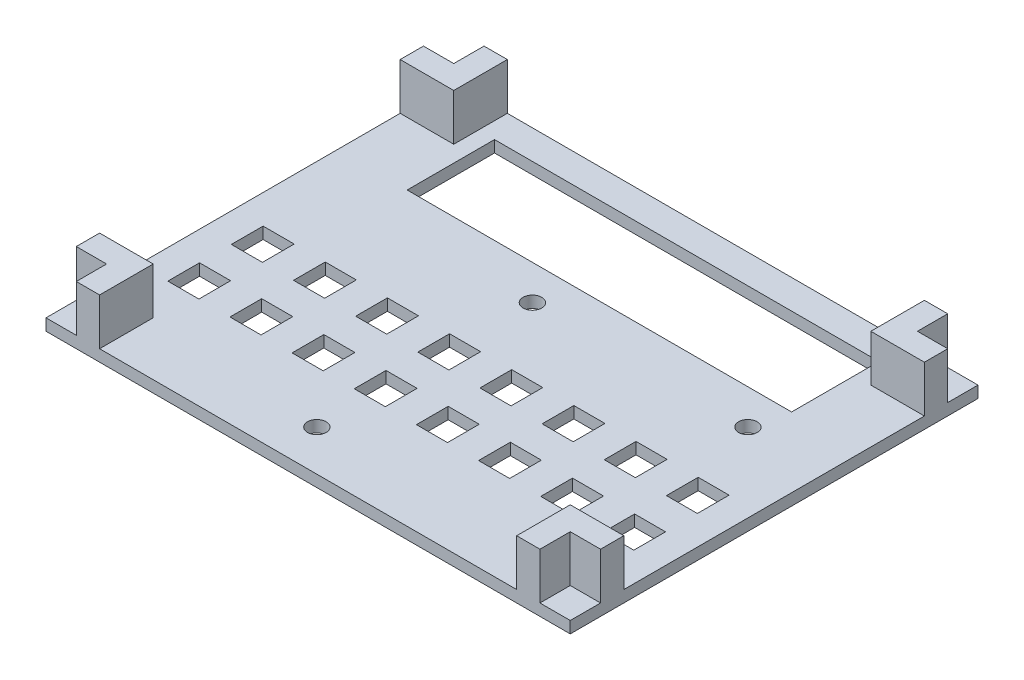
from build123d import *

# Parameters (mm, degrees)
ESBO_O1_W                = 90
ESBO_O1_H                = 70
RESSALTO_EXTRUS_O1_DEPTH = 2
RESSALTO_EXTRUS_O4_DEPTH = 8
ESBO_O6_W                = 66
ESBO_O6_H                = 15
CORTE_EXTRUS_O4_DEPTH    = 3
ESBO_O2_W                = 5.334
ESBO_O2_H                = 5.45
ESBO_O2_W_2              = 5.31
CORTE_EXTRUS_O6_DEPTH    = 5
ESBO_O7_R                = 1.6
CORTE_EXTRUS_O7_DEPTH    = 3


with BuildPart() as part:
    # Esboço1 → Ressalto-extrusão1 (new body)
    with BuildSketch(Plane(origin=(0, 0, 0), x_dir=(1, 0, 0), z_dir=(0, 1, 0))):
        Rectangle(ESBO_O1_W, ESBO_O1_H)
    extrude(amount=RESSALTO_EXTRUS_O1_DEPTH)

    # Esboço3 → Ressalto-extrusão4 (add)
    with BuildSketch(Plane(origin=(0, 2, 0), x_dir=(1, 0, 0), z_dir=(0, 1, 0))):
        Polygon((-35.8, -25.8), (-45, -25.8), (-45, -29.8), (-39.8, -29.8), (-39.8, -35), (-35.8, -35), align=None)
        Polygon((45, -29.8), (45, -25.8), (35.8, -25.8), (35.8, -35), (39.8, -35), (39.8, -29.8), align=None)
        Polygon((39.8, 35), (35.8, 35), (35.8, 25.8), (45, 25.8), (45, 29.8), (39.8, 29.8), align=None)
        Polygon((-35.8, 35), (-39.8, 35), (-39.8, 29.8), (-45, 29.8), (-45, 25.8), (-35.8, 25.8), align=None)
    extrude(amount=RESSALTO_EXTRUS_O4_DEPTH)

    # Esboço6 → Corte-extrusão4 (cut)
    with BuildSketch(Plane.XZ):
        with Locations((0, -22.5)):
            Rectangle(ESBO_O6_W, ESBO_O6_H)
    extrude(amount=-CORTE_EXTRUS_O4_DEPTH, mode=Mode.SUBTRACT)

    # Esboço2 → Corte-extrusão6 (cut)
    with BuildSketch(Plane(origin=(0, 2, 0), x_dir=(1, 0, 0), z_dir=(0, 1, 0))):
        with Locations((-37.333, -16.365)):
            Rectangle(ESBO_O2_W, ESBO_O2_H)
        with Locations((-37.333, -5.455)):
            Rectangle(ESBO_O2_W, ESBO_O2_H)
        with Locations((-26.663, -16.365)):
            Rectangle(ESBO_O2_W, ESBO_O2_H)
        with Locations((-26.663, -5.455)):
            Rectangle(ESBO_O2_W, ESBO_O2_H)
        with Locations((-15.993, -16.365)):
            Rectangle(ESBO_O2_W, ESBO_O2_H)
        with Locations((-15.993, -5.455)):
            Rectangle(ESBO_O2_W, ESBO_O2_H)
        with Locations((-5.323, -16.365)):
            Rectangle(ESBO_O2_W, ESBO_O2_H)
        with Locations((-5.323, -5.455)):
            Rectangle(ESBO_O2_W, ESBO_O2_H)
        with Locations((5.347, -16.365)):
            Rectangle(ESBO_O2_W, ESBO_O2_H)
        with Locations((5.347, -5.455)):
            Rectangle(ESBO_O2_W, ESBO_O2_H)
        with Locations((16.017, -16.365)):
            Rectangle(ESBO_O2_W, ESBO_O2_H)
        with Locations((16.017, -5.455)):
            Rectangle(ESBO_O2_W, ESBO_O2_H)
        with Locations((26.687, -16.365)):
            Rectangle(ESBO_O2_W, ESBO_O2_H)
        with Locations((26.687, -5.455)):
            Rectangle(ESBO_O2_W, ESBO_O2_H)
        with Locations((37.345, -16.365)):
            Rectangle(ESBO_O2_W_2, ESBO_O2_H)
        with Locations((37.345, -5.455)):
            Rectangle(ESBO_O2_W_2, ESBO_O2_H)
    extrude(amount=-CORTE_EXTRUS_O6_DEPTH, mode=Mode.SUBTRACT)

    # Esboço7 → Corte-extrusão7 (cut)
    with BuildSketch(Plane(origin=(0, 2, 0), x_dir=(1, 0, 0), z_dir=(0, 1, 0))):
        with Locations((31.5, 9)):
            Circle(ESBO_O7_R)
        with Locations((-5.5, 9)):
            Circle(ESBO_O7_R)
        with Locations((-5.5, -28)):
            Circle(ESBO_O7_R)
        with Locations((31.5, -28)):
            Circle(ESBO_O7_R)
    extrude(amount=-CORTE_EXTRUS_O7_DEPTH, mode=Mode.SUBTRACT)


solid = part.part
